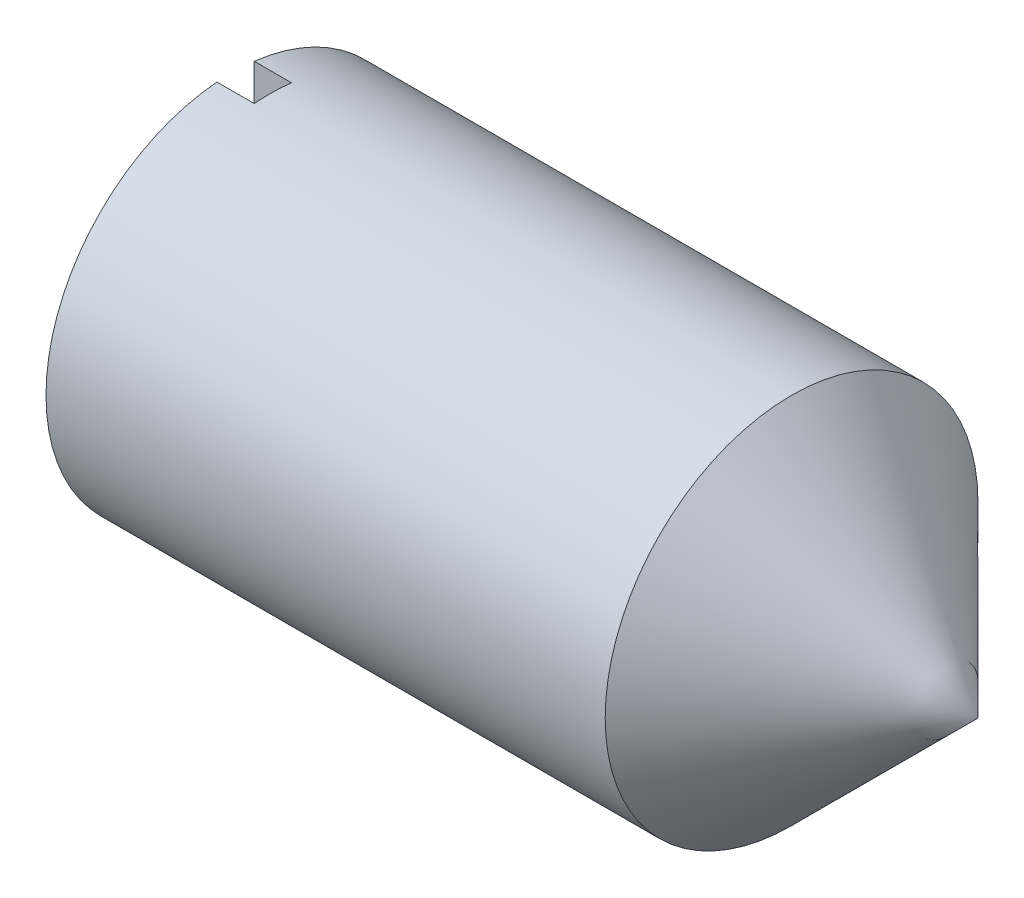
from build123d import *

# Parameters (mm, degrees)
SKETCH1_W          = 7.62
SKETCH1_H          = 2.54
SKETCH2_W          = 0.508
SKETCH2_H          = 5.430732337
CUT_EXTRUDE1_DEPTH = 0.508


with BuildPart() as part:
    # Sketch1 → Revolve1 (revolve)
    with BuildSketch(Plane(origin=(0, 0, 0), x_dir=(1, 0, 0), z_dir=(0, 1, 0))):
        Polygon((7.62, -2.54), (10.16, -2.54), (7.62, 0), align=None)
        with Locations((3.81, -1.27)):
            Rectangle(SKETCH1_W, SKETCH1_H)
    revolve(axis=Axis((10.16, 0, 2.54), (-1, 0, 0)))

    # Sketch2 → Cut-Extrude1 (cut)
    with BuildSketch(Plane.ZY):
        with Locations((2.496486647, -0.018862031)):
            Rectangle(SKETCH2_W, SKETCH2_H)
    extrude(amount=-CUT_EXTRUDE1_DEPTH, mode=Mode.SUBTRACT)


solid = part.part
